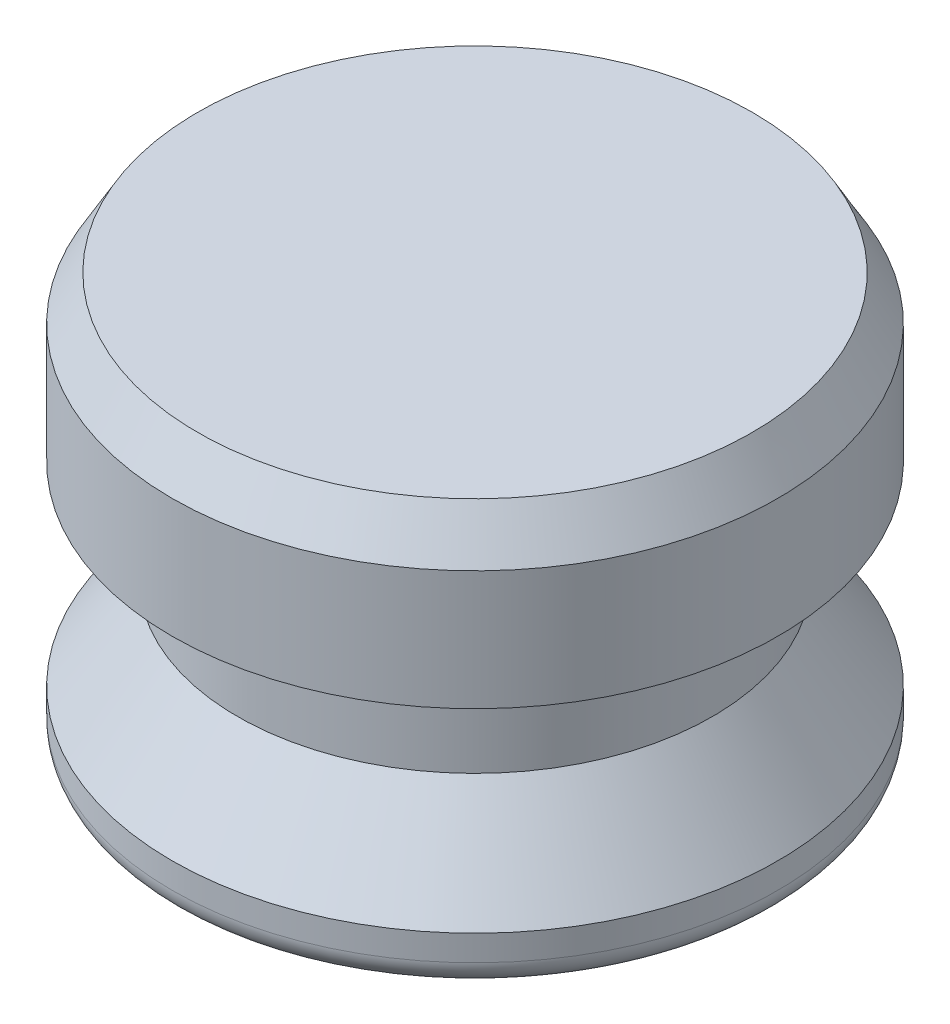
from build123d import *

# Parameters (mm, degrees)
FILLET1_R      = 0.79375
CHAMFER1_SIZE  = 0.79375
CHAMFER1_SIZE2 = 1.374815329


with BuildPart() as part:
    # Sketch1 → Revolve1 (revolve)
    with BuildSketch(Plane.XY):
        Polygon((0, 0), (-9.398, 0), (-9.398, 1.5875), (-7.366, 4.445), (-7.366, 7.62), (-9.398, 7.62), (-9.398, 12.7), (0, 12.7), align=None)
    revolve(axis=Axis((0, 0, 0), (0, 1, 0)))

    # Fillet1
    fillet1_edges = [part.edges().sort_by_distance(p)[0] for p in [
        (9.398, 0, 0),
    ]]
    fillet(fillet1_edges, radius=FILLET1_R)

    # Chamfer1
    chamfer1_edges = [part.edges().sort_by_distance(p)[0] for p in [
        (9.398, 12.7, 0),
    ]]
    chamfer1_side = [part.faces().sort_by_distance(p)[0] for p in [
        (0, 12.7, 0),
    ]]
    chamfer(chamfer1_edges, length=CHAMFER1_SIZE, length2=CHAMFER1_SIZE2, reference=chamfer1_side[0])


solid = part.part
